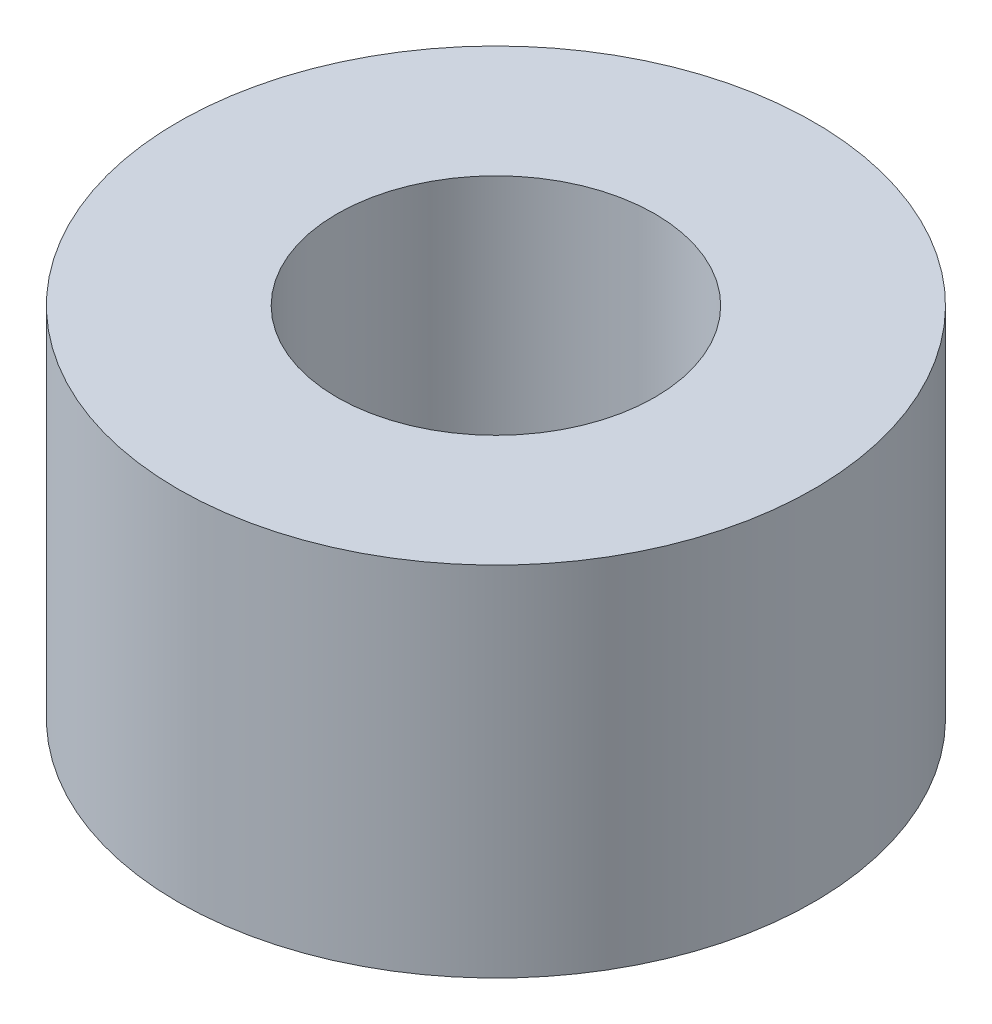
from build123d import *

# Parameters (mm, degrees)
SKETCH1_R           = 4
SKETCH1_R_2         = 2
BOSS_EXTRUDE1_DEPTH = 4.5


with BuildPart() as part:
    # Sketch1 → Boss-Extrude1 (new body)
    with BuildSketch(Plane(origin=(0, 0, 0), x_dir=(1, 0, 0), z_dir=(0, 1, 0))):
        Circle(SKETCH1_R)
        Circle(SKETCH1_R_2, mode=Mode.SUBTRACT)
    extrude(amount=BOSS_EXTRUDE1_DEPTH)


solid = part.part
